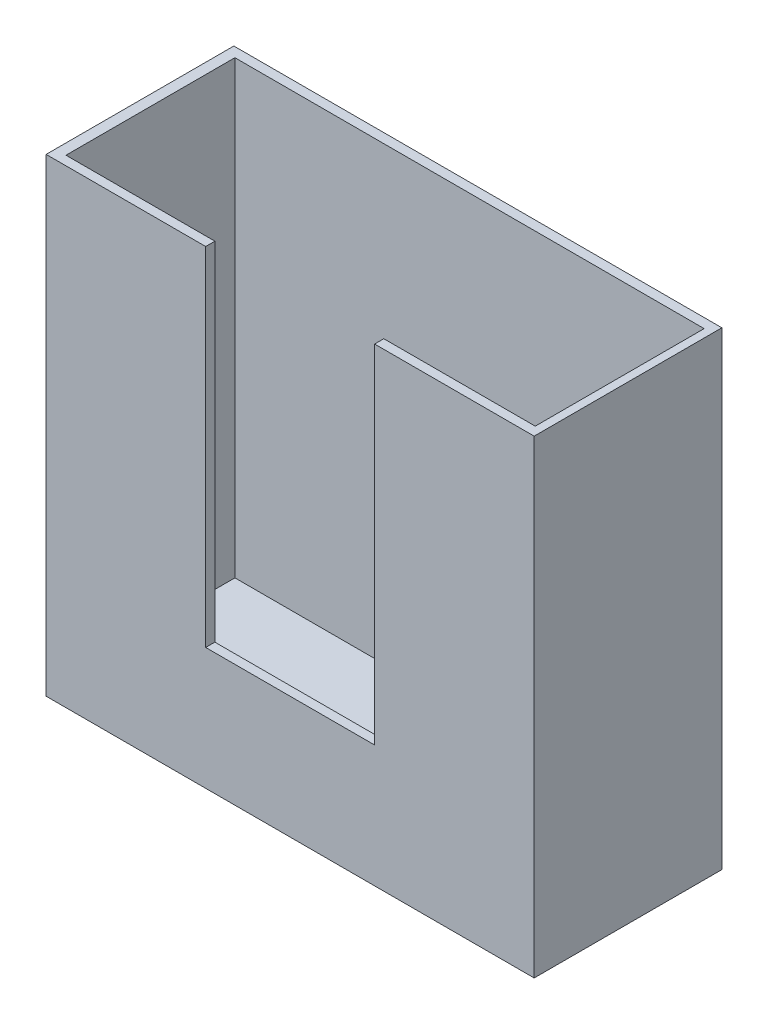
from build123d import *

# Parameters (mm, degrees)
SKETCH1_W           = 26
SKETCH1_H           = 25
BOSS_EXTRUDE1_DEPTH = 10
SKETCH2_W           = 25
SKETCH2_H           = 9
CUT_EXTRUDE1_DEPTH  = 24
SKETCH3_W           = 9
SKETCH3_H           = 18.5
CUT_EXTRUDE2_DEPTH  = 5


with BuildPart() as part:
    # Sketch1 → Boss-Extrude1 (new body)
    with BuildSketch(Plane.XY):
        Rectangle(SKETCH1_W, SKETCH1_H)
    extrude(amount=BOSS_EXTRUDE1_DEPTH)

    # Sketch2 → Cut-Extrude1 (cut)
    with BuildSketch(Plane(origin=(0, 12.5, 0), x_dir=(1, 0, 0), z_dir=(0, 1, 0))):
        with Locations((0.067812243, -5.010506078)):
            Rectangle(SKETCH2_W, SKETCH2_H)
    extrude(amount=-CUT_EXTRUDE1_DEPTH, mode=Mode.SUBTRACT)

    # Sketch3 → Cut-Extrude2 (cut)
    with BuildSketch(Plane.XY.offset(10)):
        with Locations((0, 3.25)):
            Rectangle(SKETCH3_W, SKETCH3_H)
    extrude(amount=-CUT_EXTRUDE2_DEPTH, mode=Mode.SUBTRACT)


solid = part.part
